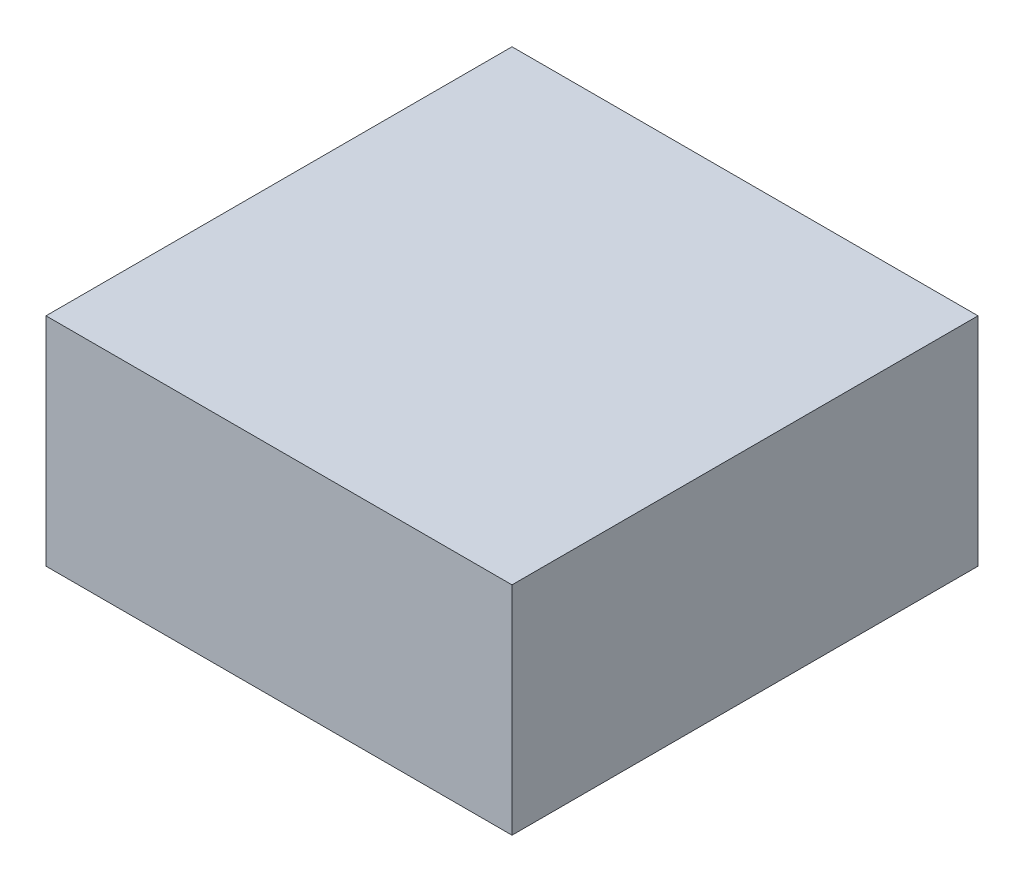
from build123d import *

# Parameters (mm, degrees)
SKETCH1_W           = 50.5
SKETCH1_H           = 50.5
BOSS_EXTRUDE1_DEPTH = 23.5


with BuildPart() as part:
    # Sketch1 → Boss-Extrude1 (new body)
    with BuildSketch(Plane(origin=(0, 0, 0), x_dir=(1, 0, 0), z_dir=(0, 1, 0))):
        Rectangle(SKETCH1_W, SKETCH1_H)
    extrude(amount=BOSS_EXTRUDE1_DEPTH)


solid = part.part
